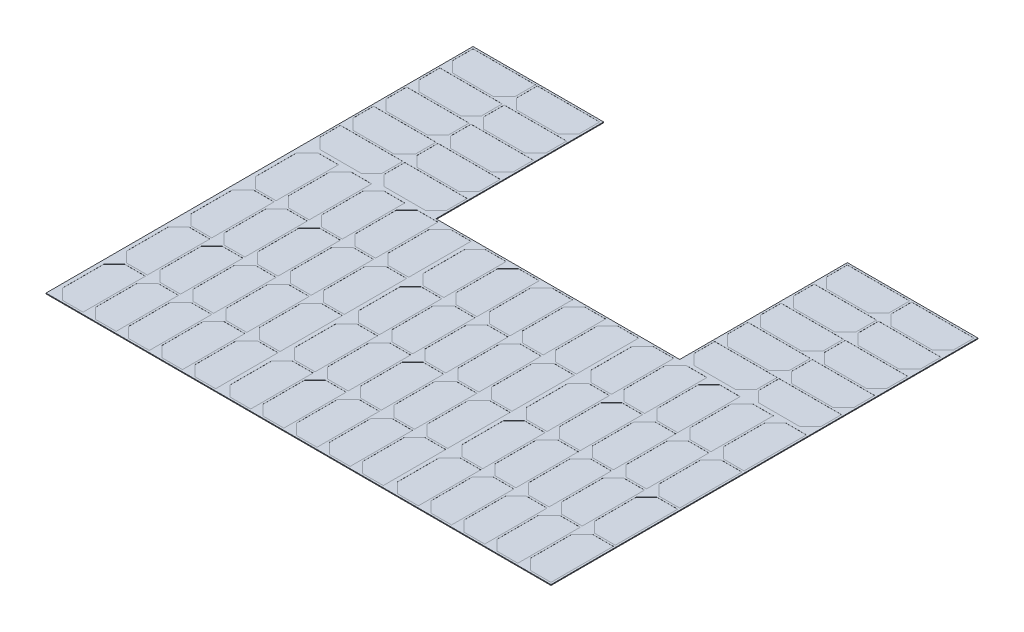
from build123d import *

# Parameters (mm, degrees)
BOSS_EXTRUDE1_DEPTH     = 1
CUT_EXTRUDE1_DEPTH      = 0.11
LPATTERN1_COUNT         = 5
LPATTERN1_PITCH         = 42.5
LPATTERN1_COUNT_DIR2    = 4
LPATTERN1_PITCH_DIR2    = 82.5
LPATTERN2_COUNT         = 3
LPATTERN2_PITCH         = 215
LPATTERN2_COPY_1_DEPTH  = 0.11
LPATTERN2_COPY_2_DEPTH  = 0.11
LPATTERN2_COPY_3_DEPTH  = 0.11
LPATTERN2_COPY_4_DEPTH  = 0.11
LPATTERN2_COPY_5_DEPTH  = 0.11
LPATTERN2_COPY_6_DEPTH  = 0.11
LPATTERN2_COPY_7_DEPTH  = 0.11
LPATTERN2_COPY_8_DEPTH  = 0.11
LPATTERN2_COPY_9_DEPTH  = 0.11
LPATTERN2_COPY_10_DEPTH = 0.11
LPATTERN2_COPY_11_DEPTH = 0.11
LPATTERN2_COPY_12_DEPTH = 0.11
LPATTERN2_COPY_13_DEPTH = 0.11
LPATTERN2_COPY_14_DEPTH = 0.11
LPATTERN2_COPY_15_DEPTH = 0.11
LPATTERN2_COPY_16_DEPTH = 0.11
LPATTERN2_COPY_17_DEPTH = 0.11
LPATTERN2_COPY_18_DEPTH = 0.11
LPATTERN2_COPY_19_DEPTH = 0.11
LPATTERN2_COPY_20_DEPTH = 0.11
LPATTERN2_COPY_21_DEPTH = 0.11
LPATTERN2_COPY_22_DEPTH = 0.11
LPATTERN2_COPY_23_DEPTH = 0.11
LPATTERN2_COPY_24_DEPTH = 0.11
LPATTERN2_COPY_25_DEPTH = 0.11
LPATTERN2_COPY_26_DEPTH = 0.11
LPATTERN2_COPY_27_DEPTH = 0.11
LPATTERN2_COPY_28_DEPTH = 0.11
LPATTERN2_COPY_29_DEPTH = 0.11
LPATTERN2_COPY_30_DEPTH = 0.11
LPATTERN2_COPY_31_DEPTH = 0.11
LPATTERN2_COPY_32_DEPTH = 0.11
LPATTERN2_COPY_33_DEPTH = 0.11
LPATTERN2_COPY_34_DEPTH = 0.11
LPATTERN2_COPY_35_DEPTH = 0.11
LPATTERN2_COPY_36_DEPTH = 0.11
LPATTERN2_COPY_37_DEPTH = 0.11
LPATTERN2_COPY_38_DEPTH = 0.11
CUT_EXTRUDE2_DEPTH      = 0.11
LPATTERN3_COUNT         = 5
LPATTERN3_PITCH         = 42.5
LPATTERN3_COUNT_DIR2    = 2
LPATTERN3_PITCH_DIR2    = 82.5
LPATTERN4_COUNT         = 2
LPATTERN4_PITCH         = 480
LPATTERN4_COPY_1_DEPTH  = 0.11
LPATTERN4_COPY_2_DEPTH  = 0.11
LPATTERN4_COPY_3_DEPTH  = 0.11
LPATTERN4_COPY_4_DEPTH  = 0.11
LPATTERN4_COPY_5_DEPTH  = 0.11
LPATTERN4_COPY_6_DEPTH  = 0.11
LPATTERN4_COPY_7_DEPTH  = 0.11
LPATTERN4_COPY_8_DEPTH  = 0.11
LPATTERN4_COPY_9_DEPTH  = 0.11


with BuildPart() as part:
    # Sketch1 → Boss-Extrude1 (new body)
    with BuildSketch(Plane(origin=(0, 0, 0), x_dir=(1, 0, 0), z_dir=(0, 1, 0))):
        Polygon((-107.057823129, 273.282312925), (-107.057823129, 58.282312925), (205.442176871, 58.282312925), (205.442176871, 273.282312925), (372.942176871, 273.282312925), (372.942176871, -274.217687075), (-274.557823129, -274.217687075), (-274.557823129, 273.282312925), align=None)
    extrude(amount=BOSS_EXTRUDE1_DEPTH)

    # Sketch2 → Cut-Extrude1 (cut)
    with BuildSketch(Plane(origin=(0, 1, 0), x_dir=(1, 0, 0), z_dir=(0, 1, 0))):
        Polygon((-269.557823129, -205.217687075), (-269.557823129, -258.217687075), (-256.057823129, -271.717687075), (-229.557823129, -271.717687075), (-229.557823129, -191.717687075), (-256.057823129, -191.717687075), align=None)
    cut_extrude1 = extrude(amount=-CUT_EXTRUDE1_DEPTH, mode=Mode.SUBTRACT)

    # LPattern1: Cut-Extrude1 5 × 4
    with Locations(*[(i * LPATTERN1_PITCH, 0, -j * LPATTERN1_PITCH_DIR2) for i in range(LPATTERN1_COUNT) for j in range(LPATTERN1_COUNT_DIR2) if (i, j) != (0, 0)]):
        add(cut_extrude1, mode=Mode.SUBTRACT)

    # LPattern2: Cut-Extrude1 ×3
    with Locations(*[(i * LPATTERN2_PITCH, 0, 0) for i in range(1, LPATTERN2_COUNT)]):
        add(cut_extrude1, mode=Mode.SUBTRACT)

    # LPattern2 copy 1 sketch → LPattern2 copy 1 (cut)
    with BuildSketch(Plane(origin=(215, 1, -82.5), x_dir=(1, 0, 0), z_dir=(0, 1, 0))):
        Polygon((-269.557823129, -205.217687075), (-269.557823129, -258.217687075), (-256.057823129, -271.717687075), (-229.557823129, -271.717687075), (-229.557823129, -191.717687075), (-256.057823129, -191.717687075), align=None)
    extrude(amount=-LPATTERN2_COPY_1_DEPTH, mode=Mode.SUBTRACT)

    # LPattern2 copy 2 sketch → LPattern2 copy 2 (cut)
    with BuildSketch(Plane(origin=(430, 1, -82.5), x_dir=(1, 0, 0), z_dir=(0, 1, 0))):
        Polygon((-269.557823129, -205.217687075), (-269.557823129, -258.217687075), (-256.057823129, -271.717687075), (-229.557823129, -271.717687075), (-229.557823129, -191.717687075), (-256.057823129, -191.717687075), align=None)
    extrude(amount=-LPATTERN2_COPY_2_DEPTH, mode=Mode.SUBTRACT)

    # LPattern2 copy 3 sketch → LPattern2 copy 3 (cut)
    with BuildSketch(Plane(origin=(215, 1, -165), x_dir=(1, 0, 0), z_dir=(0, 1, 0))):
        Polygon((-269.557823129, -205.217687075), (-269.557823129, -258.217687075), (-256.057823129, -271.717687075), (-229.557823129, -271.717687075), (-229.557823129, -191.717687075), (-256.057823129, -191.717687075), align=None)
    extrude(amount=-LPATTERN2_COPY_3_DEPTH, mode=Mode.SUBTRACT)

    # LPattern2 copy 4 sketch → LPattern2 copy 4 (cut)
    with BuildSketch(Plane(origin=(430, 1, -165), x_dir=(1, 0, 0), z_dir=(0, 1, 0))):
        Polygon((-269.557823129, -205.217687075), (-269.557823129, -258.217687075), (-256.057823129, -271.717687075), (-229.557823129, -271.717687075), (-229.557823129, -191.717687075), (-256.057823129, -191.717687075), align=None)
    extrude(amount=-LPATTERN2_COPY_4_DEPTH, mode=Mode.SUBTRACT)

    # LPattern2 copy 5 sketch → LPattern2 copy 5 (cut)
    with BuildSketch(Plane(origin=(215, 1, -247.5), x_dir=(1, 0, 0), z_dir=(0, 1, 0))):
        Polygon((-269.557823129, -205.217687075), (-269.557823129, -258.217687075), (-256.057823129, -271.717687075), (-229.557823129, -271.717687075), (-229.557823129, -191.717687075), (-256.057823129, -191.717687075), align=None)
    extrude(amount=-LPATTERN2_COPY_5_DEPTH, mode=Mode.SUBTRACT)

    # LPattern2 copy 6 sketch → LPattern2 copy 6 (cut)
    with BuildSketch(Plane(origin=(430, 1, -247.5), x_dir=(1, 0, 0), z_dir=(0, 1, 0))):
        Polygon((-269.557823129, -205.217687075), (-269.557823129, -258.217687075), (-256.057823129, -271.717687075), (-229.557823129, -271.717687075), (-229.557823129, -191.717687075), (-256.057823129, -191.717687075), align=None)
    extrude(amount=-LPATTERN2_COPY_6_DEPTH, mode=Mode.SUBTRACT)

    # LPattern2 copy 7 sketch → LPattern2 copy 7 (cut)
    with BuildSketch(Plane(origin=(257.5, 1, 0), x_dir=(1, 0, 0), z_dir=(0, 1, 0))):
        Polygon((-269.557823129, -205.217687075), (-269.557823129, -258.217687075), (-256.057823129, -271.717687075), (-229.557823129, -271.717687075), (-229.557823129, -191.717687075), (-256.057823129, -191.717687075), align=None)
    extrude(amount=-LPATTERN2_COPY_7_DEPTH, mode=Mode.SUBTRACT)

    # LPattern2 copy 8 sketch → LPattern2 copy 8 (cut)
    with BuildSketch(Plane(origin=(472.5, 1, 0), x_dir=(1, 0, 0), z_dir=(0, 1, 0))):
        Polygon((-269.557823129, -205.217687075), (-269.557823129, -258.217687075), (-256.057823129, -271.717687075), (-229.557823129, -271.717687075), (-229.557823129, -191.717687075), (-256.057823129, -191.717687075), align=None)
    extrude(amount=-LPATTERN2_COPY_8_DEPTH, mode=Mode.SUBTRACT)

    # LPattern2 copy 9 sketch → LPattern2 copy 9 (cut)
    with BuildSketch(Plane(origin=(257.5, 1, -82.5), x_dir=(1, 0, 0), z_dir=(0, 1, 0))):
        Polygon((-269.557823129, -205.217687075), (-269.557823129, -258.217687075), (-256.057823129, -271.717687075), (-229.557823129, -271.717687075), (-229.557823129, -191.717687075), (-256.057823129, -191.717687075), align=None)
    extrude(amount=-LPATTERN2_COPY_9_DEPTH, mode=Mode.SUBTRACT)

    # LPattern2 copy 10 sketch → LPattern2 copy 10 (cut)
    with BuildSketch(Plane(origin=(472.5, 1, -82.5), x_dir=(1, 0, 0), z_dir=(0, 1, 0))):
        Polygon((-269.557823129, -205.217687075), (-269.557823129, -258.217687075), (-256.057823129, -271.717687075), (-229.557823129, -271.717687075), (-229.557823129, -191.717687075), (-256.057823129, -191.717687075), align=None)
    extrude(amount=-LPATTERN2_COPY_10_DEPTH, mode=Mode.SUBTRACT)

    # LPattern2 copy 11 sketch → LPattern2 copy 11 (cut)
    with BuildSketch(Plane(origin=(257.5, 1, -165), x_dir=(1, 0, 0), z_dir=(0, 1, 0))):
        Polygon((-269.557823129, -205.217687075), (-269.557823129, -258.217687075), (-256.057823129, -271.717687075), (-229.557823129, -271.717687075), (-229.557823129, -191.717687075), (-256.057823129, -191.717687075), align=None)
    extrude(amount=-LPATTERN2_COPY_11_DEPTH, mode=Mode.SUBTRACT)

    # LPattern2 copy 12 sketch → LPattern2 copy 12 (cut)
    with BuildSketch(Plane(origin=(472.5, 1, -165), x_dir=(1, 0, 0), z_dir=(0, 1, 0))):
        Polygon((-269.557823129, -205.217687075), (-269.557823129, -258.217687075), (-256.057823129, -271.717687075), (-229.557823129, -271.717687075), (-229.557823129, -191.717687075), (-256.057823129, -191.717687075), align=None)
    extrude(amount=-LPATTERN2_COPY_12_DEPTH, mode=Mode.SUBTRACT)

    # LPattern2 copy 13 sketch → LPattern2 copy 13 (cut)
    with BuildSketch(Plane(origin=(257.5, 1, -247.5), x_dir=(1, 0, 0), z_dir=(0, 1, 0))):
        Polygon((-269.557823129, -205.217687075), (-269.557823129, -258.217687075), (-256.057823129, -271.717687075), (-229.557823129, -271.717687075), (-229.557823129, -191.717687075), (-256.057823129, -191.717687075), align=None)
    extrude(amount=-LPATTERN2_COPY_13_DEPTH, mode=Mode.SUBTRACT)

    # LPattern2 copy 14 sketch → LPattern2 copy 14 (cut)
    with BuildSketch(Plane(origin=(472.5, 1, -247.5), x_dir=(1, 0, 0), z_dir=(0, 1, 0))):
        Polygon((-269.557823129, -205.217687075), (-269.557823129, -258.217687075), (-256.057823129, -271.717687075), (-229.557823129, -271.717687075), (-229.557823129, -191.717687075), (-256.057823129, -191.717687075), align=None)
    extrude(amount=-LPATTERN2_COPY_14_DEPTH, mode=Mode.SUBTRACT)

    # LPattern2 copy 15 sketch → LPattern2 copy 15 (cut)
    with BuildSketch(Plane(origin=(300, 1, 0), x_dir=(1, 0, 0), z_dir=(0, 1, 0))):
        Polygon((-269.557823129, -205.217687075), (-269.557823129, -258.217687075), (-256.057823129, -271.717687075), (-229.557823129, -271.717687075), (-229.557823129, -191.717687075), (-256.057823129, -191.717687075), align=None)
    extrude(amount=-LPATTERN2_COPY_15_DEPTH, mode=Mode.SUBTRACT)

    # LPattern2 copy 16 sketch → LPattern2 copy 16 (cut)
    with BuildSketch(Plane(origin=(515, 1, 0), x_dir=(1, 0, 0), z_dir=(0, 1, 0))):
        Polygon((-269.557823129, -205.217687075), (-269.557823129, -258.217687075), (-256.057823129, -271.717687075), (-229.557823129, -271.717687075), (-229.557823129, -191.717687075), (-256.057823129, -191.717687075), align=None)
    extrude(amount=-LPATTERN2_COPY_16_DEPTH, mode=Mode.SUBTRACT)

    # LPattern2 copy 17 sketch → LPattern2 copy 17 (cut)
    with BuildSketch(Plane(origin=(300, 1, -82.5), x_dir=(1, 0, 0), z_dir=(0, 1, 0))):
        Polygon((-269.557823129, -205.217687075), (-269.557823129, -258.217687075), (-256.057823129, -271.717687075), (-229.557823129, -271.717687075), (-229.557823129, -191.717687075), (-256.057823129, -191.717687075), align=None)
    extrude(amount=-LPATTERN2_COPY_17_DEPTH, mode=Mode.SUBTRACT)

    # LPattern2 copy 18 sketch → LPattern2 copy 18 (cut)
    with BuildSketch(Plane(origin=(515, 1, -82.5), x_dir=(1, 0, 0), z_dir=(0, 1, 0))):
        Polygon((-269.557823129, -205.217687075), (-269.557823129, -258.217687075), (-256.057823129, -271.717687075), (-229.557823129, -271.717687075), (-229.557823129, -191.717687075), (-256.057823129, -191.717687075), align=None)
    extrude(amount=-LPATTERN2_COPY_18_DEPTH, mode=Mode.SUBTRACT)

    # LPattern2 copy 19 sketch → LPattern2 copy 19 (cut)
    with BuildSketch(Plane(origin=(300, 1, -165), x_dir=(1, 0, 0), z_dir=(0, 1, 0))):
        Polygon((-269.557823129, -205.217687075), (-269.557823129, -258.217687075), (-256.057823129, -271.717687075), (-229.557823129, -271.717687075), (-229.557823129, -191.717687075), (-256.057823129, -191.717687075), align=None)
    extrude(amount=-LPATTERN2_COPY_19_DEPTH, mode=Mode.SUBTRACT)

    # LPattern2 copy 20 sketch → LPattern2 copy 20 (cut)
    with BuildSketch(Plane(origin=(515, 1, -165), x_dir=(1, 0, 0), z_dir=(0, 1, 0))):
        Polygon((-269.557823129, -205.217687075), (-269.557823129, -258.217687075), (-256.057823129, -271.717687075), (-229.557823129, -271.717687075), (-229.557823129, -191.717687075), (-256.057823129, -191.717687075), align=None)
    extrude(amount=-LPATTERN2_COPY_20_DEPTH, mode=Mode.SUBTRACT)

    # LPattern2 copy 21 sketch → LPattern2 copy 21 (cut)
    with BuildSketch(Plane(origin=(300, 1, -247.5), x_dir=(1, 0, 0), z_dir=(0, 1, 0))):
        Polygon((-269.557823129, -205.217687075), (-269.557823129, -258.217687075), (-256.057823129, -271.717687075), (-229.557823129, -271.717687075), (-229.557823129, -191.717687075), (-256.057823129, -191.717687075), align=None)
    extrude(amount=-LPATTERN2_COPY_21_DEPTH, mode=Mode.SUBTRACT)

    # LPattern2 copy 22 sketch → LPattern2 copy 22 (cut)
    with BuildSketch(Plane(origin=(515, 1, -247.5), x_dir=(1, 0, 0), z_dir=(0, 1, 0))):
        Polygon((-269.557823129, -205.217687075), (-269.557823129, -258.217687075), (-256.057823129, -271.717687075), (-229.557823129, -271.717687075), (-229.557823129, -191.717687075), (-256.057823129, -191.717687075), align=None)
    extrude(amount=-LPATTERN2_COPY_22_DEPTH, mode=Mode.SUBTRACT)

    # LPattern2 copy 23 sketch → LPattern2 copy 23 (cut)
    with BuildSketch(Plane(origin=(342.5, 1, 0), x_dir=(1, 0, 0), z_dir=(0, 1, 0))):
        Polygon((-269.557823129, -205.217687075), (-269.557823129, -258.217687075), (-256.057823129, -271.717687075), (-229.557823129, -271.717687075), (-229.557823129, -191.717687075), (-256.057823129, -191.717687075), align=None)
    extrude(amount=-LPATTERN2_COPY_23_DEPTH, mode=Mode.SUBTRACT)

    # LPattern2 copy 24 sketch → LPattern2 copy 24 (cut)
    with BuildSketch(Plane(origin=(557.5, 1, 0), x_dir=(1, 0, 0), z_dir=(0, 1, 0))):
        Polygon((-269.557823129, -205.217687075), (-269.557823129, -258.217687075), (-256.057823129, -271.717687075), (-229.557823129, -271.717687075), (-229.557823129, -191.717687075), (-256.057823129, -191.717687075), align=None)
    extrude(amount=-LPATTERN2_COPY_24_DEPTH, mode=Mode.SUBTRACT)

    # LPattern2 copy 25 sketch → LPattern2 copy 25 (cut)
    with BuildSketch(Plane(origin=(342.5, 1, -82.5), x_dir=(1, 0, 0), z_dir=(0, 1, 0))):
        Polygon((-269.557823129, -205.217687075), (-269.557823129, -258.217687075), (-256.057823129, -271.717687075), (-229.557823129, -271.717687075), (-229.557823129, -191.717687075), (-256.057823129, -191.717687075), align=None)
    extrude(amount=-LPATTERN2_COPY_25_DEPTH, mode=Mode.SUBTRACT)

    # LPattern2 copy 26 sketch → LPattern2 copy 26 (cut)
    with BuildSketch(Plane(origin=(557.5, 1, -82.5), x_dir=(1, 0, 0), z_dir=(0, 1, 0))):
        Polygon((-269.557823129, -205.217687075), (-269.557823129, -258.217687075), (-256.057823129, -271.717687075), (-229.557823129, -271.717687075), (-229.557823129, -191.717687075), (-256.057823129, -191.717687075), align=None)
    extrude(amount=-LPATTERN2_COPY_26_DEPTH, mode=Mode.SUBTRACT)

    # LPattern2 copy 27 sketch → LPattern2 copy 27 (cut)
    with BuildSketch(Plane(origin=(342.5, 1, -165), x_dir=(1, 0, 0), z_dir=(0, 1, 0))):
        Polygon((-269.557823129, -205.217687075), (-269.557823129, -258.217687075), (-256.057823129, -271.717687075), (-229.557823129, -271.717687075), (-229.557823129, -191.717687075), (-256.057823129, -191.717687075), align=None)
    extrude(amount=-LPATTERN2_COPY_27_DEPTH, mode=Mode.SUBTRACT)

    # LPattern2 copy 28 sketch → LPattern2 copy 28 (cut)
    with BuildSketch(Plane(origin=(557.5, 1, -165), x_dir=(1, 0, 0), z_dir=(0, 1, 0))):
        Polygon((-269.557823129, -205.217687075), (-269.557823129, -258.217687075), (-256.057823129, -271.717687075), (-229.557823129, -271.717687075), (-229.557823129, -191.717687075), (-256.057823129, -191.717687075), align=None)
    extrude(amount=-LPATTERN2_COPY_28_DEPTH, mode=Mode.SUBTRACT)

    # LPattern2 copy 29 sketch → LPattern2 copy 29 (cut)
    with BuildSketch(Plane(origin=(342.5, 1, -247.5), x_dir=(1, 0, 0), z_dir=(0, 1, 0))):
        Polygon((-269.557823129, -205.217687075), (-269.557823129, -258.217687075), (-256.057823129, -271.717687075), (-229.557823129, -271.717687075), (-229.557823129, -191.717687075), (-256.057823129, -191.717687075), align=None)
    extrude(amount=-LPATTERN2_COPY_29_DEPTH, mode=Mode.SUBTRACT)

    # LPattern2 copy 30 sketch → LPattern2 copy 30 (cut)
    with BuildSketch(Plane(origin=(557.5, 1, -247.5), x_dir=(1, 0, 0), z_dir=(0, 1, 0))):
        Polygon((-269.557823129, -205.217687075), (-269.557823129, -258.217687075), (-256.057823129, -271.717687075), (-229.557823129, -271.717687075), (-229.557823129, -191.717687075), (-256.057823129, -191.717687075), align=None)
    extrude(amount=-LPATTERN2_COPY_30_DEPTH, mode=Mode.SUBTRACT)

    # LPattern2 copy 31 sketch → LPattern2 copy 31 (cut)
    with BuildSketch(Plane(origin=(385, 1, 0), x_dir=(1, 0, 0), z_dir=(0, 1, 0))):
        Polygon((-269.557823129, -205.217687075), (-269.557823129, -258.217687075), (-256.057823129, -271.717687075), (-229.557823129, -271.717687075), (-229.557823129, -191.717687075), (-256.057823129, -191.717687075), align=None)
    extrude(amount=-LPATTERN2_COPY_31_DEPTH, mode=Mode.SUBTRACT)

    # LPattern2 copy 32 sketch → LPattern2 copy 32 (cut)
    with BuildSketch(Plane(origin=(600, 1, 0), x_dir=(1, 0, 0), z_dir=(0, 1, 0))):
        Polygon((-269.557823129, -205.217687075), (-269.557823129, -258.217687075), (-256.057823129, -271.717687075), (-229.557823129, -271.717687075), (-229.557823129, -191.717687075), (-256.057823129, -191.717687075), align=None)
    extrude(amount=-LPATTERN2_COPY_32_DEPTH, mode=Mode.SUBTRACT)

    # LPattern2 copy 33 sketch → LPattern2 copy 33 (cut)
    with BuildSketch(Plane(origin=(385, 1, -82.5), x_dir=(1, 0, 0), z_dir=(0, 1, 0))):
        Polygon((-269.557823129, -205.217687075), (-269.557823129, -258.217687075), (-256.057823129, -271.717687075), (-229.557823129, -271.717687075), (-229.557823129, -191.717687075), (-256.057823129, -191.717687075), align=None)
    extrude(amount=-LPATTERN2_COPY_33_DEPTH, mode=Mode.SUBTRACT)

    # LPattern2 copy 34 sketch → LPattern2 copy 34 (cut)
    with BuildSketch(Plane(origin=(600, 1, -82.5), x_dir=(1, 0, 0), z_dir=(0, 1, 0))):
        Polygon((-269.557823129, -205.217687075), (-269.557823129, -258.217687075), (-256.057823129, -271.717687075), (-229.557823129, -271.717687075), (-229.557823129, -191.717687075), (-256.057823129, -191.717687075), align=None)
    extrude(amount=-LPATTERN2_COPY_34_DEPTH, mode=Mode.SUBTRACT)

    # LPattern2 copy 35 sketch → LPattern2 copy 35 (cut)
    with BuildSketch(Plane(origin=(385, 1, -165), x_dir=(1, 0, 0), z_dir=(0, 1, 0))):
        Polygon((-269.557823129, -205.217687075), (-269.557823129, -258.217687075), (-256.057823129, -271.717687075), (-229.557823129, -271.717687075), (-229.557823129, -191.717687075), (-256.057823129, -191.717687075), align=None)
    extrude(amount=-LPATTERN2_COPY_35_DEPTH, mode=Mode.SUBTRACT)

    # LPattern2 copy 36 sketch → LPattern2 copy 36 (cut)
    with BuildSketch(Plane(origin=(600, 1, -165), x_dir=(1, 0, 0), z_dir=(0, 1, 0))):
        Polygon((-269.557823129, -205.217687075), (-269.557823129, -258.217687075), (-256.057823129, -271.717687075), (-229.557823129, -271.717687075), (-229.557823129, -191.717687075), (-256.057823129, -191.717687075), align=None)
    extrude(amount=-LPATTERN2_COPY_36_DEPTH, mode=Mode.SUBTRACT)

    # LPattern2 copy 37 sketch → LPattern2 copy 37 (cut)
    with BuildSketch(Plane(origin=(385, 1, -247.5), x_dir=(1, 0, 0), z_dir=(0, 1, 0))):
        Polygon((-269.557823129, -205.217687075), (-269.557823129, -258.217687075), (-256.057823129, -271.717687075), (-229.557823129, -271.717687075), (-229.557823129, -191.717687075), (-256.057823129, -191.717687075), align=None)
    extrude(amount=-LPATTERN2_COPY_37_DEPTH, mode=Mode.SUBTRACT)

    # LPattern2 copy 38 sketch → LPattern2 copy 38 (cut)
    with BuildSketch(Plane(origin=(600, 1, -247.5), x_dir=(1, 0, 0), z_dir=(0, 1, 0))):
        Polygon((-269.557823129, -205.217687075), (-269.557823129, -258.217687075), (-256.057823129, -271.717687075), (-229.557823129, -271.717687075), (-229.557823129, -191.717687075), (-256.057823129, -191.717687075), align=None)
    extrude(amount=-LPATTERN2_COPY_38_DEPTH, mode=Mode.SUBTRACT)

    # Sketch3 → Cut-Extrude2 (cut)
    with BuildSketch(Plane(origin=(0, 1, 0), x_dir=(1, 0, 0), z_dir=(0, 1, 0))):
        Polygon((-272.057823129, 74.282312925), (-272.057823129, 100.782312925), (-192.057823129, 100.782312925), (-192.057823129, 74.282312925), (-205.557823129, 60.782312925), (-258.557823129, 60.782312925), align=None)
    cut_extrude2 = extrude(amount=-CUT_EXTRUDE2_DEPTH, mode=Mode.SUBTRACT)

    # LPattern3: Cut-Extrude2 5 × 2
    with Locations(*[(j * LPATTERN3_PITCH_DIR2, 0, -i * LPATTERN3_PITCH) for i in range(LPATTERN3_COUNT) for j in range(LPATTERN3_COUNT_DIR2) if (i, j) != (0, 0)]):
        add(cut_extrude2, mode=Mode.SUBTRACT)

    # LPattern4: Cut-Extrude2 ×2
    with Locations(*[(i * LPATTERN4_PITCH, 0, 0) for i in range(1, LPATTERN4_COUNT)]):
        add(cut_extrude2, mode=Mode.SUBTRACT)

    # LPattern4 copy 1 sketch → LPattern4 copy 1 (cut)
    with BuildSketch(Plane(origin=(562.5, 1, 0), x_dir=(1, 0, 0), z_dir=(0, 1, 0))):
        Polygon((-272.057823129, 74.282312925), (-272.057823129, 100.782312925), (-192.057823129, 100.782312925), (-192.057823129, 74.282312925), (-205.557823129, 60.782312925), (-258.557823129, 60.782312925), align=None)
    extrude(amount=-LPATTERN4_COPY_1_DEPTH, mode=Mode.SUBTRACT)

    # LPattern4 copy 2 sketch → LPattern4 copy 2 (cut)
    with BuildSketch(Plane(origin=(480, 1, -42.5), x_dir=(1, 0, 0), z_dir=(0, 1, 0))):
        Polygon((-272.057823129, 74.282312925), (-272.057823129, 100.782312925), (-192.057823129, 100.782312925), (-192.057823129, 74.282312925), (-205.557823129, 60.782312925), (-258.557823129, 60.782312925), align=None)
    extrude(amount=-LPATTERN4_COPY_2_DEPTH, mode=Mode.SUBTRACT)

    # LPattern4 copy 3 sketch → LPattern4 copy 3 (cut)
    with BuildSketch(Plane(origin=(562.5, 1, -42.5), x_dir=(1, 0, 0), z_dir=(0, 1, 0))):
        Polygon((-272.057823129, 74.282312925), (-272.057823129, 100.782312925), (-192.057823129, 100.782312925), (-192.057823129, 74.282312925), (-205.557823129, 60.782312925), (-258.557823129, 60.782312925), align=None)
    extrude(amount=-LPATTERN4_COPY_3_DEPTH, mode=Mode.SUBTRACT)

    # LPattern4 copy 4 sketch → LPattern4 copy 4 (cut)
    with BuildSketch(Plane(origin=(480, 1, -85), x_dir=(1, 0, 0), z_dir=(0, 1, 0))):
        Polygon((-272.057823129, 74.282312925), (-272.057823129, 100.782312925), (-192.057823129, 100.782312925), (-192.057823129, 74.282312925), (-205.557823129, 60.782312925), (-258.557823129, 60.782312925), align=None)
    extrude(amount=-LPATTERN4_COPY_4_DEPTH, mode=Mode.SUBTRACT)

    # LPattern4 copy 5 sketch → LPattern4 copy 5 (cut)
    with BuildSketch(Plane(origin=(562.5, 1, -85), x_dir=(1, 0, 0), z_dir=(0, 1, 0))):
        Polygon((-272.057823129, 74.282312925), (-272.057823129, 100.782312925), (-192.057823129, 100.782312925), (-192.057823129, 74.282312925), (-205.557823129, 60.782312925), (-258.557823129, 60.782312925), align=None)
    extrude(amount=-LPATTERN4_COPY_5_DEPTH, mode=Mode.SUBTRACT)

    # LPattern4 copy 6 sketch → LPattern4 copy 6 (cut)
    with BuildSketch(Plane(origin=(480, 1, -127.5), x_dir=(1, 0, 0), z_dir=(0, 1, 0))):
        Polygon((-272.057823129, 74.282312925), (-272.057823129, 100.782312925), (-192.057823129, 100.782312925), (-192.057823129, 74.282312925), (-205.557823129, 60.782312925), (-258.557823129, 60.782312925), align=None)
    extrude(amount=-LPATTERN4_COPY_6_DEPTH, mode=Mode.SUBTRACT)

    # LPattern4 copy 7 sketch → LPattern4 copy 7 (cut)
    with BuildSketch(Plane(origin=(562.5, 1, -127.5), x_dir=(1, 0, 0), z_dir=(0, 1, 0))):
        Polygon((-272.057823129, 74.282312925), (-272.057823129, 100.782312925), (-192.057823129, 100.782312925), (-192.057823129, 74.282312925), (-205.557823129, 60.782312925), (-258.557823129, 60.782312925), align=None)
    extrude(amount=-LPATTERN4_COPY_7_DEPTH, mode=Mode.SUBTRACT)

    # LPattern4 copy 8 sketch → LPattern4 copy 8 (cut)
    with BuildSketch(Plane(origin=(480, 1, -170), x_dir=(1, 0, 0), z_dir=(0, 1, 0))):
        Polygon((-272.057823129, 74.282312925), (-272.057823129, 100.782312925), (-192.057823129, 100.782312925), (-192.057823129, 74.282312925), (-205.557823129, 60.782312925), (-258.557823129, 60.782312925), align=None)
    extrude(amount=-LPATTERN4_COPY_8_DEPTH, mode=Mode.SUBTRACT)

    # LPattern4 copy 9 sketch → LPattern4 copy 9 (cut)
    with BuildSketch(Plane(origin=(562.5, 1, -170), x_dir=(1, 0, 0), z_dir=(0, 1, 0))):
        Polygon((-272.057823129, 74.282312925), (-272.057823129, 100.782312925), (-192.057823129, 100.782312925), (-192.057823129, 74.282312925), (-205.557823129, 60.782312925), (-258.557823129, 60.782312925), align=None)
    extrude(amount=-LPATTERN4_COPY_9_DEPTH, mode=Mode.SUBTRACT)


solid = part.part
